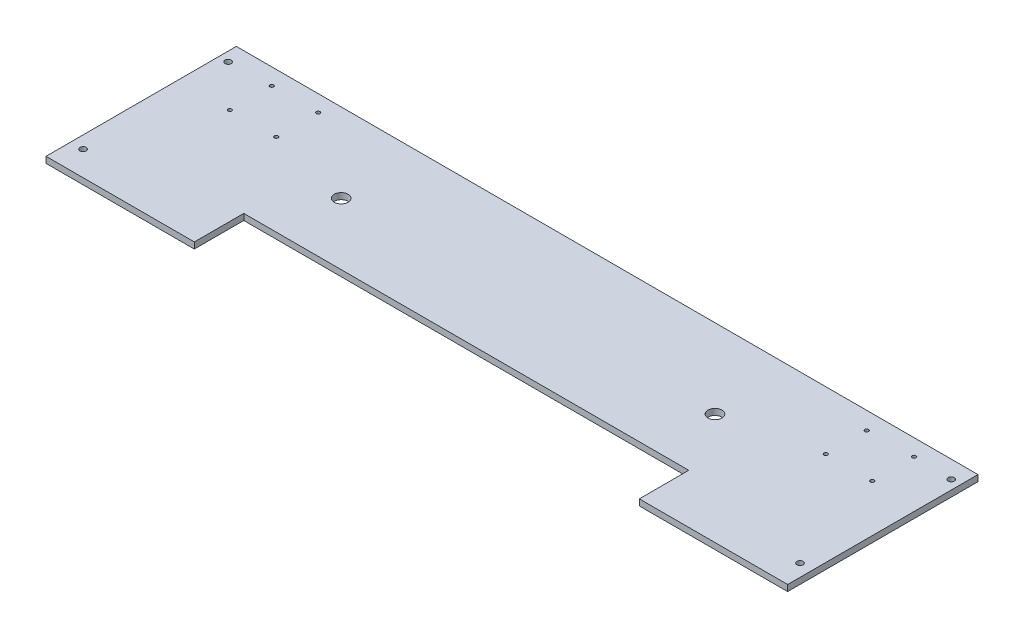
from build123d import *

# Parameters (mm, degrees)
BOSS_EXTRUDE1_DEPTH = 6.35
SKETCH3_R           = 3.175
SKETCH3_R_2         = 1.905
SKETCH3_R_3         = 7.14375
CUT_EXTRUDE1_DEPTH  = 7.62


with BuildPart() as part:
    # Sketch1 → Boss-Extrude1 (new body)
    with BuildSketch(Plane(origin=(0, 0, 0), x_dir=(1, 0, 0), z_dir=(0, 1, 0))):
        Polygon((0, 0), (457.2, 0), (457.2, -50.8), (609.6, -50.8), (609.6, 144.78), (-152.4, 144.78), (-152.4, -50.8), (0, -50.8), align=None)
    extrude(amount=BOSS_EXTRUDE1_DEPTH)

    # Sketch3 → Cut-Extrude1 (cut)
    with BuildSketch(Plane(origin=(0, 6.35, 0), x_dir=(1, 0, 0), z_dir=(0, 1, 0))):
        with Locations((-139.7, -25.4)):
            Circle(SKETCH3_R)
        with Locations((-99.1108, 84.8106)):
            Circle(SKETCH3_R_2)
        with Locations((-142.875, 126.81712)):
            Circle(SKETCH3_R)
        with Locations((-51.435, 84.8106)):
            Circle(SKETCH3_R_2)
        with Locations((-51.435, 127.8636)):
            Circle(SKETCH3_R_2)
        with Locations((36.576, 63.5)):
            Circle(SKETCH3_R_3)
        with Locations((600.075, 126.81712)):
            Circle(SKETCH3_R)
        with Locations((596.9, -25.4)):
            Circle(SKETCH3_R)
        with Locations((560.959, 127.8636)):
            Circle(SKETCH3_R_2)
        with Locations((513.207, 84.8106)):
            Circle(SKETCH3_R_2)
        with Locations((560.959, 84.8106)):
            Circle(SKETCH3_R_2)
        with Locations((513.207, 126.81712)):
            Circle(SKETCH3_R_2)
        with Locations((420.624, 63.5)):
            Circle(SKETCH3_R_3)
        with Locations((-99.1108, 127.8636)):
            Circle(SKETCH3_R_2)
    extrude(amount=-CUT_EXTRUDE1_DEPTH, mode=Mode.SUBTRACT)


solid = part.part
